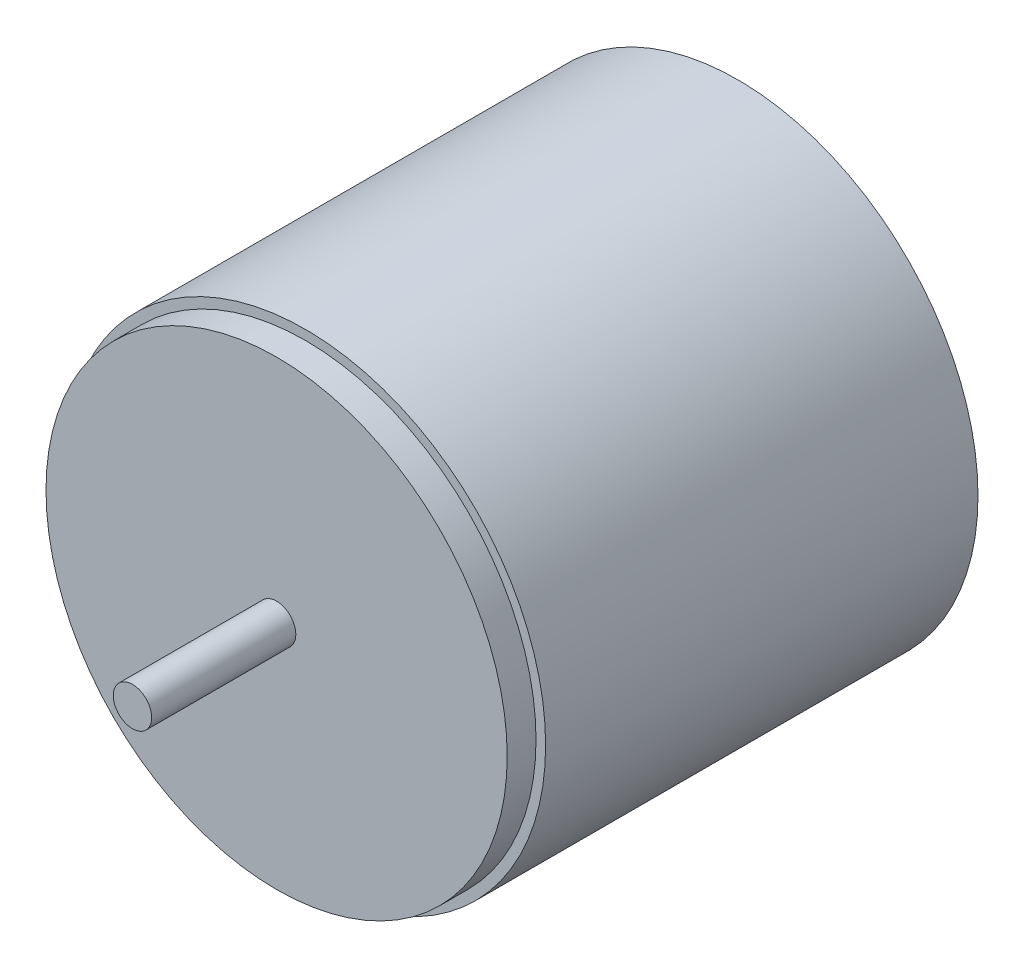
from build123d import *

# Parameters (mm, degrees)
SKETCH1_R           = 25
BOSS_EXTRUDE1_DEPTH = 45
SKETCH2_R           = 24
BOSS_EXTRUDE2_DEPTH = 48
SKETCH3_R           = 2
BOSS_EXTRUDE3_DEPTH = 63


with BuildPart() as part:
    # Sketch1 → Boss-Extrude1 (new body)
    with BuildSketch(Plane.XY):
        Circle(SKETCH1_R)
    extrude(amount=BOSS_EXTRUDE1_DEPTH)

    # Sketch2 → Boss-Extrude2 (add)
    with BuildSketch(Plane.XY):
        Circle(SKETCH2_R)
    extrude(amount=BOSS_EXTRUDE2_DEPTH)

    # Sketch3 → Boss-Extrude3 (add)
    with BuildSketch(Plane.XY):
        Circle(SKETCH3_R)
    extrude(amount=BOSS_EXTRUDE3_DEPTH)


solid = part.part
